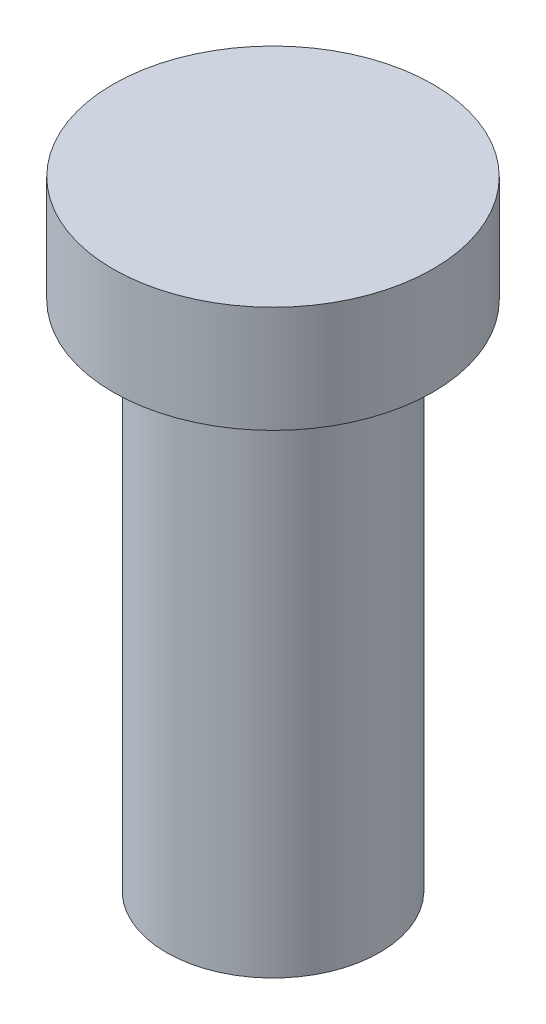
from build123d import *

# Parameters (mm, degrees)
SKETCH1_R           = 2.5
BOSS_EXTRUDE1_DEPTH = 12
SKETCH2_R           = 3.75
BOSS_EXTRUDE2_DEPTH = 2.5


with BuildPart() as part:
    # Sketch1 → Boss-Extrude1 (new body)
    with BuildSketch(Plane(origin=(0, 0, 0), x_dir=(1, 0, 0), z_dir=(0, 1, 0))):
        Circle(SKETCH1_R)
    extrude(amount=BOSS_EXTRUDE1_DEPTH)

    # Sketch2 → Boss-Extrude2 (add)
    with BuildSketch(Plane(origin=(0, 12, 0), x_dir=(1, 0, 0), z_dir=(0, 1, 0))):
        Circle(SKETCH2_R)
    extrude(amount=BOSS_EXTRUDE2_DEPTH)


solid = part.part
